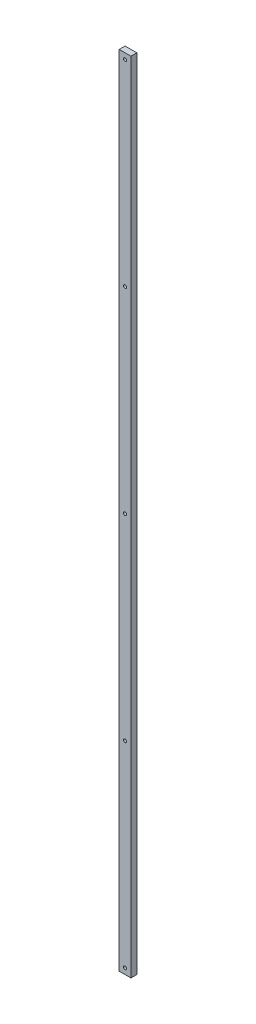
from build123d import *

# Parameters (mm, degrees)
SKETCH1_W           = 25.4
SKETCH1_H           = 1727.2
BOSS_EXTRUDE1_DEPTH = 12.7
SKETCH2_R           = 3.3655
CUT_EXTRUDE1_DEPTH  = 13.7
LPATTERN1_COUNT     = 5
LPATTERN1_PITCH     = 425.45


with BuildPart() as part:
    # Sketch1 → Boss-Extrude1 (new body)
    with BuildSketch(Plane.XY):
        with Locations((12.7, 863.6)):
            Rectangle(SKETCH1_W, SKETCH1_H)
    extrude(amount=BOSS_EXTRUDE1_DEPTH)

    # Sketch2 → Cut-Extrude1 (cut, through all)
    with BuildSketch(Plane.XY.offset(12.7)):
        with Locations((12.7, 12.7)):
            Circle(SKETCH2_R)
    cut_extrude1 = extrude(amount=-CUT_EXTRUDE1_DEPTH, mode=Mode.SUBTRACT)

    # LPattern1: Cut-Extrude1 ×5
    with Locations(*[(0, i * LPATTERN1_PITCH, 0) for i in range(1, LPATTERN1_COUNT)]):
        add(cut_extrude1, mode=Mode.SUBTRACT)


solid = part.part
